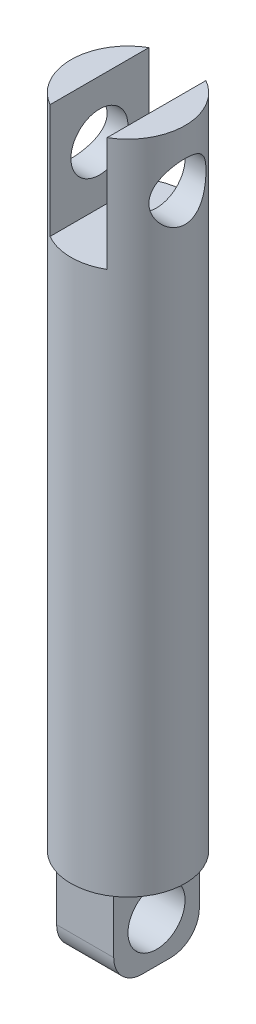
from build123d import *

# Parameters (mm, degrees)
SKETCH1_R               = 10
BOSS_EXTRUDE1_DEPTH     = 95
SKETCH4_W               = 10
SKETCH4_H               = 15
BOSS_EXTRUDE3_DEPTH     = 15
SKETCH5_R               = 5
CUT_EXTRUDE2_DEPTH      = 15
FILLET1_R               = 5
SKETCH9_R               = 10
BOSS_EXTRUDE4_DEPTH     = 20
SKETCH10_W              = 10
SKETCH10_H              = 36.273756528
CUT_EXTRUDE4_DEPTH      = 20
SKETCH12_R              = 5
CUT_EXTRUDE5_DEPTH      = 11
CUT_EXTRUDE5_DEPTH_BACK = 11


with BuildPart() as part:
    # Sketch1 → Boss-Extrude1 (new body)
    with BuildSketch(Plane(origin=(0, 0, 0), x_dir=(1, 0, 0), z_dir=(0, 1, 0))):
        Circle(SKETCH1_R)
    extrude(amount=BOSS_EXTRUDE1_DEPTH)

    # Sketch4 → Boss-Extrude3 (add)
    with BuildSketch(Plane.XZ):
        Rectangle(SKETCH4_W, SKETCH4_H)
    extrude(amount=BOSS_EXTRUDE3_DEPTH)

    # Sketch5 → Cut-Extrude2 (cut)
    with BuildSketch(Plane.ZY.offset(5)):
        with Locations((0, -7.5)):
            Circle(SKETCH5_R)
    extrude(amount=-CUT_EXTRUDE2_DEPTH, mode=Mode.SUBTRACT)

    # Fillet1
    fillet1_edges = [part.edges().sort_by_distance(p)[0] for p in [
        (0, -15, -7.5),
        (0, -15, 7.5),
    ]]
    fillet(fillet1_edges, radius=FILLET1_R)

    # Sketch9 → Boss-Extrude4 (add)
    with BuildSketch(Plane(origin=(0, 95, 0), x_dir=(1, 0, 0), z_dir=(0, 1, 0))):
        Circle(SKETCH9_R)
    extrude(amount=BOSS_EXTRUDE4_DEPTH)

    # Sketch10 → Cut-Extrude4 (cut)
    with BuildSketch(Plane(origin=(0, 115, 0), x_dir=(1, 0, 0), z_dir=(0, 1, 0))):
        Rectangle(SKETCH10_W, SKETCH10_H)
    extrude(amount=-CUT_EXTRUDE4_DEPTH, mode=Mode.SUBTRACT)

    # Sketch12 → Cut-Extrude5 (cut, two sides)
    with BuildSketch(Plane(origin=(0, 0, 0), x_dir=(0, 0, -1), z_dir=(1, 0, 0))) as cut_extrude5_sk:
        with Locations((0, 105)):
            Circle(SKETCH12_R)
    extrude(amount=CUT_EXTRUDE5_DEPTH, mode=Mode.SUBTRACT)
    extrude(cut_extrude5_sk.sketch, amount=-CUT_EXTRUDE5_DEPTH_BACK, mode=Mode.SUBTRACT)


solid = part.part
